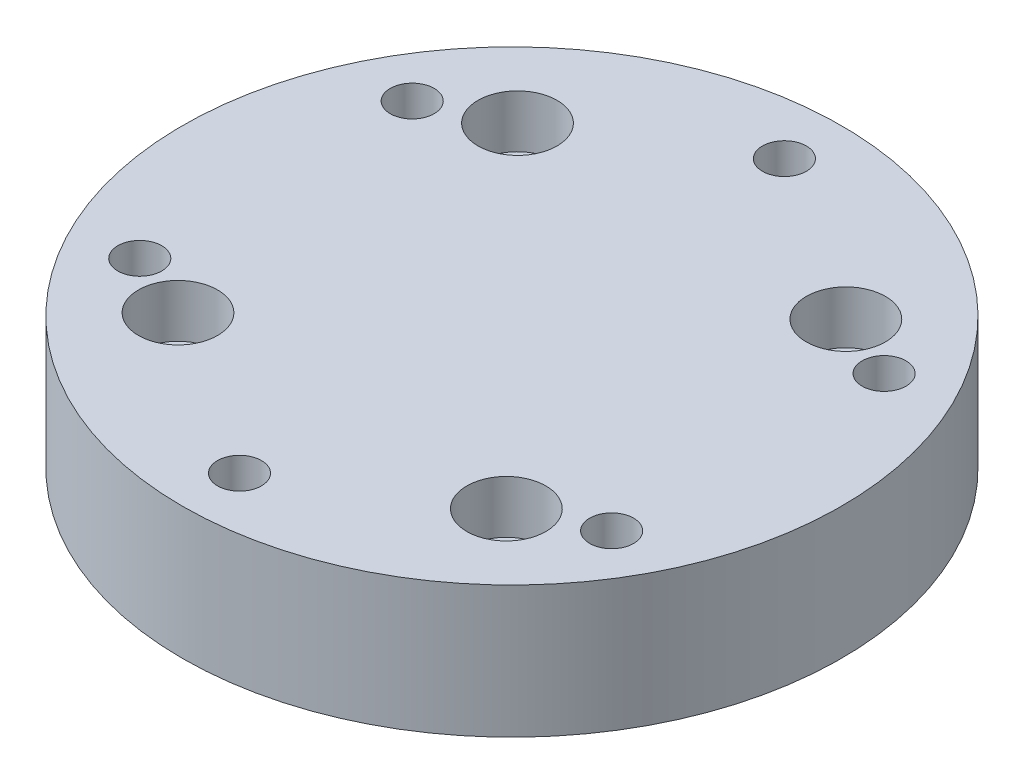
from build123d import *

# Parameters (mm, degrees)
SKETCH2_R             = 37.5
SKETCH2_R_2           = 2.5
BOSS_EXTRUDE1_DEPTH   = 15
SKETCH3_R             = 4.5
CUT_EXTRUDE1_DEPTH    = 6
M6X1_0_TAPPED_HOLE1_D = 5


with BuildPart() as part:
    # Sketch2 → Boss-Extrude1 (new body)
    with BuildSketch(Plane(origin=(0, 0, 0), x_dir=(1, 0, 0), z_dir=(0, 1, 0))):
        Circle(SKETCH2_R)
        with Locations((-18.679244128, 19.315419379)):
            Circle(SKETCH2_R_2, mode=Mode.SUBTRACT)
        with Locations((19.315419379, 18.679244128)):
            Circle(SKETCH2_R_2, mode=Mode.SUBTRACT)
        with Locations((18.679244128, -19.315419379)):
            Circle(SKETCH2_R_2, mode=Mode.SUBTRACT)
        with Locations((-19.315419379, -18.679244128)):
            Circle(SKETCH2_R_2, mode=Mode.SUBTRACT)
    extrude(amount=BOSS_EXTRUDE1_DEPTH)

    # Sketch3 → Cut-Extrude1 (cut)
    with BuildSketch(Plane(origin=(0, 15, 0), x_dir=(1, 0, 0), z_dir=(0, 1, 0))):
        with Locations((-18.679244128, 19.315419379)):
            Circle(SKETCH3_R)
        with Locations((19.315419379, 18.679244128)):
            Circle(SKETCH3_R)
        with Locations((18.679244128, -19.315419379)):
            Circle(SKETCH3_R)
        with Locations((-19.315419379, -18.679244128)):
            Circle(SKETCH3_R)
    extrude(amount=-CUT_EXTRUDE1_DEPTH, mode=Mode.SUBTRACT)

    # M6x1.0 Tapped Hole1 (through all)
    with Locations(Plane(origin=(0, 15, -31), x_dir=(0, 0, 1), z_dir=(0, 1, 0))):
        with Locations((0, 0), (15.5, 26.846787517), (46.5, 26.846787517), (62, 0), (46.5, -26.846787517), (15.5, -26.846787517)):
            Hole(M6X1_0_TAPPED_HOLE1_D / 2)


solid = part.part
